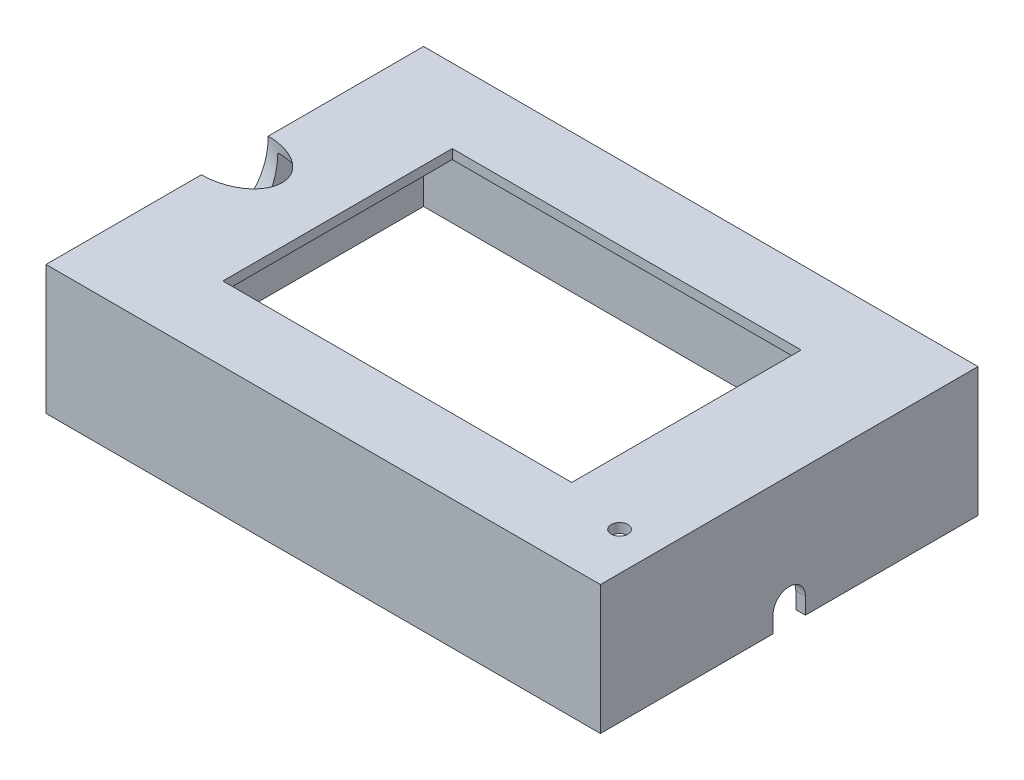
from build123d import *

# Parameters (mm, degrees)
SKETCH1_W           = 116
SKETCH1_H           = 79
SKETCH1_W_2         = 112
SKETCH1_H_2         = 75
BOSS_EXTRUDE1_DEPTH = 25
SKETCH2_W           = 116
SKETCH2_H           = 79
BOSS_EXTRUDE2_DEPTH = 2
SKETCH3_W           = 73
SKETCH3_H           = 48
CUT_EXTRUDE1_DEPTH  = 2
SKETCH4_R           = 1.75
CUT_EXTRUDE2_DEPTH  = 2
SKETCH6_R           = 7
CUT_EXTRUDE3_DEPTH  = 10
CUT_EXTRUDE4_DEPTH  = 2


with BuildPart() as part:
    # Sketch1 → Boss-Extrude1 (new body)
    with BuildSketch(Plane(origin=(0, 0, 0), x_dir=(1, 0, 0), z_dir=(0, 1, 0))):
        Rectangle(SKETCH1_W, SKETCH1_H)
        Rectangle(SKETCH1_W_2, SKETCH1_H_2, mode=Mode.SUBTRACT)
    extrude(amount=BOSS_EXTRUDE1_DEPTH)

    # Sketch2 → Boss-Extrude2 (add)
    with BuildSketch(Plane(origin=(0, 25, 0), x_dir=(1, 0, 0), z_dir=(0, 1, 0))):
        Rectangle(SKETCH2_W, SKETCH2_H)
    extrude(amount=BOSS_EXTRUDE2_DEPTH)

    # Sketch3 → Cut-Extrude1 (cut)
    with BuildSketch(Plane(origin=(0, 27, 0), x_dir=(1, 0, 0), z_dir=(0, 1, 0))):
        Rectangle(SKETCH3_W, SKETCH3_H)
    extrude(amount=-CUT_EXTRUDE1_DEPTH, mode=Mode.SUBTRACT)

    # Sketch4 → Cut-Extrude2 (cut)
    with BuildSketch(Plane(origin=(0, 27, 0), x_dir=(1, 0, 0), z_dir=(0, 1, 0))):
        with Locations((50, -27.5)):
            Circle(SKETCH4_R)
    extrude(amount=-CUT_EXTRUDE2_DEPTH, mode=Mode.SUBTRACT)

    # Sketch6 → Cut-Extrude3 (cut)
    with BuildSketch(Plane(origin=(-42.5, 42.5, 0), x_dir=(-0.707106781, -0.707106781, 0), z_dir=(0.707106781, -0.707106781, 0))):
        with Locations((21.920310217, 0)):
            Circle(SKETCH6_R)
    extrude(amount=CUT_EXTRUDE3_DEPTH, mode=Mode.SUBTRACT)

    # Sketch7 → Cut-Extrude4 (cut)
    with BuildSketch(Plane(origin=(58, 0, 0), x_dir=(0, 0, -1), z_dir=(1, 0, 0))):
        with BuildLine():
            Line((-3.375, 3.5), (-3.375, 0))
            Line((-3.375, 0), (3.375, 0))
            Line((3.375, 0), (3.375, 3.5))
            ThreePointArc((3.375, 3.5), (0, 6.875), (-3.375, 3.5))
        make_face()
    extrude(amount=-CUT_EXTRUDE4_DEPTH, mode=Mode.SUBTRACT)


solid = part.part
